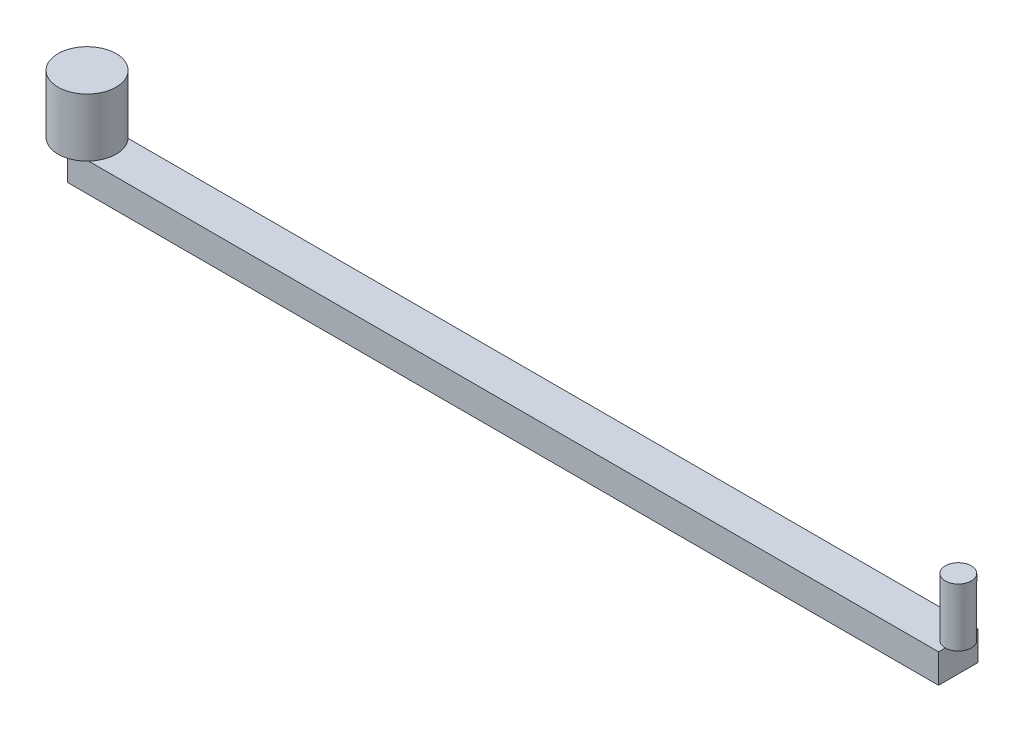
from build123d import *

# Parameters (mm, degrees)
SKETCH1_W           = 76.2
SKETCH1_H           = 3.45052473
BOSS_EXTRUDE1_DEPTH = 2.54
SKETCH2_R           = 2.54
BOSS_EXTRUDE2_DEPTH = 5.08
SKETCH3_R           = 1.143
BOSS_EXTRUDE3_DEPTH = 5.08


with BuildPart() as part:
    # Sketch1 → Boss-Extrude1 (new body)
    with BuildSketch(Plane(origin=(0, 0, 0), x_dir=(1, 0, 0), z_dir=(0, 1, 0))):
        Rectangle(SKETCH1_W, SKETCH1_H)
    extrude(amount=BOSS_EXTRUDE1_DEPTH)

    # Sketch2 → Boss-Extrude2 (add)
    with BuildSketch(Plane(origin=(0, 2.54, 0), x_dir=(1, 0, 0), z_dir=(0, 1, 0))):
        with Locations((-38.1, 0)):
            Circle(SKETCH2_R)
    extrude(amount=BOSS_EXTRUDE2_DEPTH)

    # Sketch3 → Boss-Extrude3 (add)
    with BuildSketch(Plane(origin=(0, 2.54, 0), x_dir=(1, 0, 0), z_dir=(0, 1, 0))):
        with Locations((38.1, 0)):
            Circle(SKETCH3_R)
    extrude(amount=BOSS_EXTRUDE3_DEPTH)


solid = part.part
